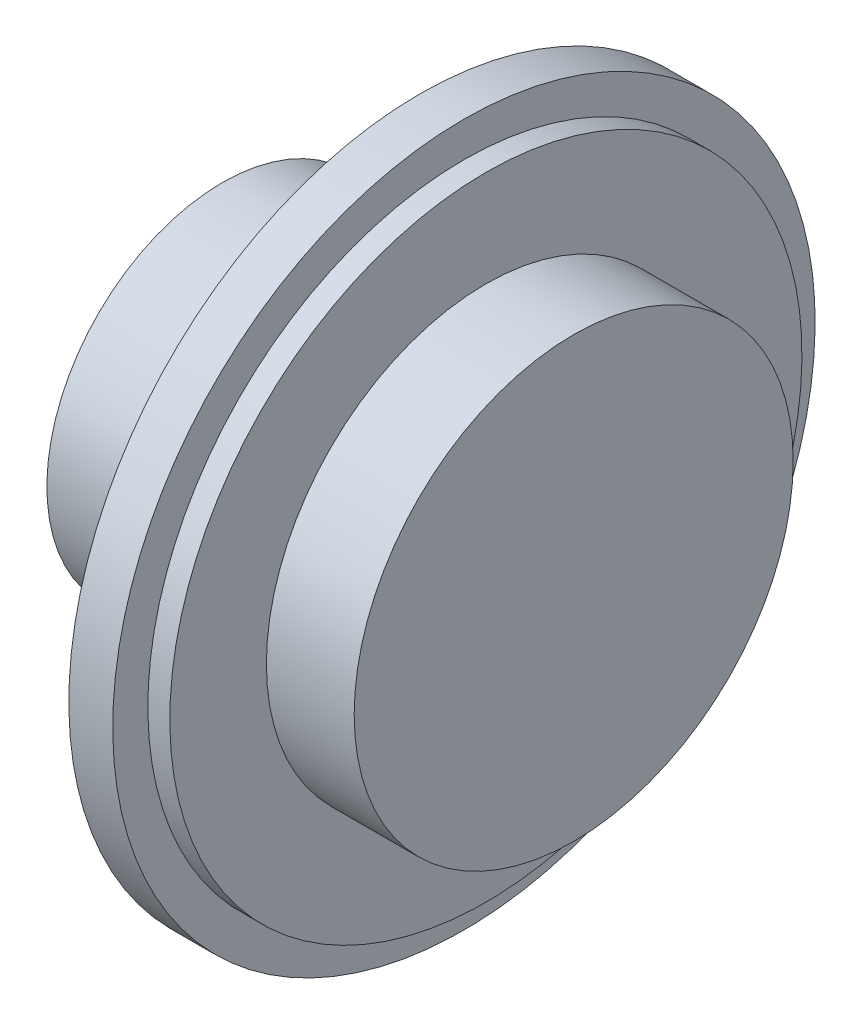
from build123d import *


with BuildPart() as part:
    # 스케치1 → 회전2 (revolve)
    with BuildSketch(Plane.XY):
        Polygon((0, 0), (0, 10), (10, 10), (10, 18), (11.25, 18), (11.25, 20), (13.75, 20), (13.75, 18), (15, 18), (15, 12.5), (20, 12.5), (20, 0), align=None)
    revolve(axis=Axis((20, 0, 0), (-1, 0, 0)))


solid = part.part
